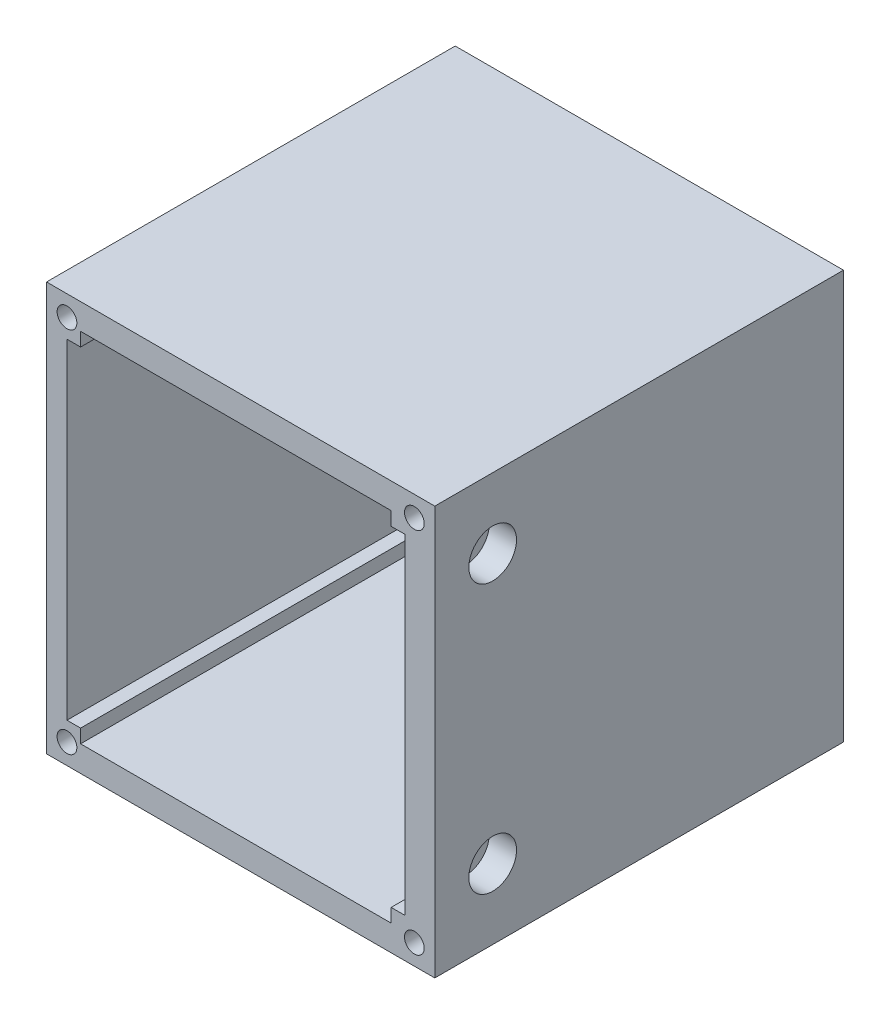
from build123d import *

# Parameters (mm, degrees)
BOSS_EXTRUDE1_DEPTH = 60
CUT_EXTRUDE1_DEPTH  = 56
CUT_EXTRUDE2_DEPTH  = 61
SKETCH9_R           = 3.5
CUT_EXTRUDE3_DEPTH  = 4
SKETCH12_W          = 2
SKETCH12_H          = 2
BOSS_EXTRUDE3_DEPTH = 56
SKETCH13_R          = 1.45
CUT_EXTRUDE5_DEPTH  = 6
SKETCH16_R          = 1.95
CUT_EXTRUDE6_DEPTH  = 4
SKETCH17_R          = 2
CUT_EXTRUDE7_DEPTH  = 4.404613


with BuildPart() as part:
    # Sketch1 → Boss-Extrude1 (new body)
    with BuildSketch(Plane.XY):
        Polygon((-17.5, 30), (-27.5, 30), (-39.5, 30), (-39.5, -30), (-27.5, -30), (-17.5, -30), (17.5, -30), (17.5, 30), align=None)
    extrude(amount=BOSS_EXTRUDE1_DEPTH)

    # Sketch3 → Cut-Extrude1 (cut)
    with BuildSketch(Plane.XY.offset(60)):
        Polygon((-13.09538708, -26.224688329), (-23.1, -26.224688329), (-36.5, -26.224688329), (-36.5, 26.224688329), (-23.1, 26.224688329), (-13.09538708, 26.224688329), (11.09538708, 26.224688329), (13.09538708, 26.224688329), (13.09538708, 0), (13.09538708, -26.224688329), (11.09538708, -26.224688329), align=None)
    extrude(amount=-CUT_EXTRUDE1_DEPTH, mode=Mode.SUBTRACT)

    # Sketch6 → Cut-Extrude2 (cut, through all)
    with BuildSketch(Plane(origin=(0, 0, 0), x_dir=(-1, 0, 0), z_dir=(0, 0, -1))):
        Polygon((4, 15), (4, 19.2), (16, 19.2), (16, 10.8), (4, 10.8), align=None)
        Polygon((16, -10.8), (4, -10.8), (4, -15), (4, -19.2), (16, -19.2), align=None)
    extrude(amount=-CUT_EXTRUDE2_DEPTH, mode=Mode.SUBTRACT)

    # Sketch9 → Cut-Extrude3 (cut)
    with BuildSketch(Plane(origin=(17.5, 0, 0), x_dir=(0, 0, -1), z_dir=(1, 0, 0))):
        with Locations((-51.5, 19.72468833)):
            Circle(SKETCH9_R)
        with Locations((-51.5, -19.72468833)):
            Circle(SKETCH9_R)
    extrude(amount=-CUT_EXTRUDE3_DEPTH, mode=Mode.SUBTRACT)

    # Sketch12 → Boss-Extrude3 (add)
    with BuildSketch(Plane.XY.offset(60)):
        with Locations((-35.5, 25.224688329)):
            Rectangle(SKETCH12_W, SKETCH12_H)
        with Locations((12.09538708, -25.224688329)):
            Rectangle(SKETCH12_W, SKETCH12_H)
        with Locations((12.09538708, 25.224688329)):
            Rectangle(SKETCH12_W, SKETCH12_H)
        with Locations((-35.5, -25.224688329)):
            Rectangle(SKETCH12_W, SKETCH12_H)
    extrude(amount=-BOSS_EXTRUDE3_DEPTH)

    # Sketch13 → Cut-Extrude5 (cut)
    with BuildSketch(Plane.XY.offset(60)):
        with Locations((-36.5, 27)):
            Circle(SKETCH13_R)
        with Locations((-36.5, -27)):
            Circle(SKETCH13_R)
        with Locations((14.5, 27)):
            Circle(SKETCH13_R)
        with Locations((14.5, -27)):
            Circle(SKETCH13_R)
    extrude(amount=-CUT_EXTRUDE5_DEPTH, mode=Mode.SUBTRACT)

    # Sketch16 → Cut-Extrude6 (cut)
    with BuildSketch(Plane.XY.offset(4)):
        with Locations((2.5, 15)):
            Circle(SKETCH16_R)
        with Locations((2.5, -15)):
            Circle(SKETCH16_R)
    extrude(amount=-CUT_EXTRUDE6_DEPTH, mode=Mode.SUBTRACT)

    # Sketch17 → Cut-Extrude7 (cut)
    with BuildSketch(Plane(origin=(17.5, 0, 0), x_dir=(0, 0, -1), z_dir=(1, 0, 0))):
        with Locations((-51.5, 19.72468833)):
            Circle(SKETCH17_R)
        with Locations((-51.5, -19.72468833)):
            Circle(SKETCH17_R)
    extrude(amount=-CUT_EXTRUDE7_DEPTH, mode=Mode.SUBTRACT)


solid = part.part
